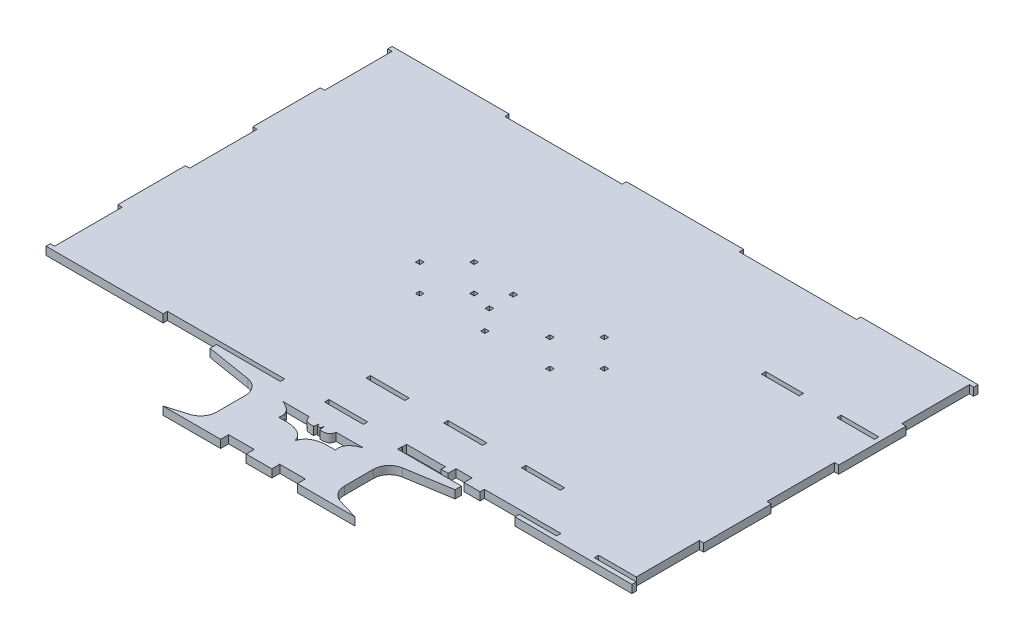
from build123d import *

# Parameters (mm, degrees)
SKETCH1_W           = 2.7
SKETCH1_H           = 2.7
SKETCH1_W_2         = 23.566666667
SKETCH1_W_3         = 24.3
BOSS_EXTRUDE1_DEPTH = 5


with BuildPart() as part:
    # Sketch1 → Boss-Extrude1 (new body)
    with BuildSketch(Plane(origin=(0, 0, 0), x_dir=(1, 0, 0), z_dir=(0, 1, 0))):
        with BuildLine():
            Line((-183.2, 108.2), (-109.92, 108.2))
            Line((-109.92, 108.2), (-109.92, 105.5))
            Line((-109.92, 105.5), (-36.64, 105.5))
            Line((-36.64, 105.5), (-36.64, 108.2))
            Line((-36.64, 108.2), (36.64, 108.2))
            Line((36.64, 108.2), (36.64, 105.5))
            Line((36.64, 105.5), (109.92, 105.5))
            Line((109.92, 105.5), (109.92, 108.2))
            Line((109.92, 108.2), (183.2, 108.2))
            Line((183.2, 108.2), (183.2, 105.5))
            Line((183.2, 105.5), (180.5, 105.5))
            Line((180.5, 105.5), (180.5, 63.3))
            Line((180.5, 63.3), (183.2, 63.3))
            Line((183.2, 63.3), (183.2, 21.1))
            Line((183.2, 21.1), (180.5, 21.1))
            Line((180.5, 21.1), (180.5, -21.1))
            Line((180.5, -21.1), (183.2, -21.1))
            Line((183.2, -21.1), (183.2, -63.3))
            Line((183.2, -63.3), (180.5, -63.3))
            Line((180.5, -63.3), (180.5, -102.8))
            Line((180.5, -102.8), (156.933333333, -102.8))
            Line((156.933333333, -102.8), (156.933333333, -105.5))
            Line((156.933333333, -105.5), (180.5, -105.5))
            Line((180.5, -105.5), (183.2, -105.5))
            Line((183.2, -105.5), (183.2, -108.2))
            Line((183.2, -108.2), (109.92, -108.2))
            Line((109.92, -108.2), (109.92, -105.5))
            Line((109.92, -105.5), (133.366666667, -105.5))
            Line((133.366666667, -105.5), (133.366666667, -102.8))
            Line((133.366666667, -102.8), (109.8, -102.8))
            Line((109.8, -102.8), (85.5, -102.8))
            Line((85.5, -102.8), (85.5, -105.5))
            Line((85.5, -105.5), (75.5, -105.5))
            Line((75.5, -105.5), (75.5, -100.5))
            Line((75.5, -100.5), (70.5, -100.5))
            Line((70.5, -100.5), (65.5, -100.5))
            Line((65.5, -100.5), (65.5, -105.5))
            Line((65.5, -105.5), (61.2, -105.5))
            Line((61.2, -105.5), (61.2, -102.8))
            Line((61.2, -102.8), (36.9, -102.8))
            Line((36.9, -102.8), (36.9, -105.5))
            Line((36.9, -105.5), (36.64, -105.5))
            Line((36.64, -105.5), (36.64, -108.2))
            Line((36.64, -108.2), (76.64, -108.2))
            Line((76.64, -108.2), (76.64, -112.2))
            Line((76.64, -112.2), (48.383969685, -116.8270792))
            ThreePointArc((48.383969685, -116.8270792), (42.378966502, -120.22108374), (40, -126.695637657))
            Line((40, -126.695637657), (40, -144.759693491))
            ThreePointArc((40, -144.759693491), (41.977070717, -150.728998787), (47.126521144, -154.337956343))
            Line((47.126521144, -154.337956343), (60, -158.2))
            Line((60, -158.2), (40, -158.2))
            Line((40, -158.2), (24, -158.2))
            Line((24, -158.2), (24, -153.2))
            Line((24, -153.2), (8, -153.2))
            Line((8, -153.2), (8, -158.2))
            Line((8, -158.2), (-8, -158.2))
            Line((-8, -158.2), (-8, -153.2))
            Line((-8, -153.2), (-24, -153.2))
            Line((-24, -153.2), (-24, -158.2))
            Line((-24, -158.2), (-40, -158.2))
            Line((-40, -158.2), (-60, -158.2))
            Line((-60, -158.2), (-47.126521144, -154.337956343))
            ThreePointArc((-47.126521144, -154.337956343), (-41.977070717, -150.728998787), (-40, -144.759693491))
            Line((-40, -144.759693491), (-40, -126.695637657))
            ThreePointArc((-40, -126.695637657), (-42.378966502, -120.22108374), (-48.383969685, -116.8270792))
            Line((-48.383969685, -116.8270792), (-76.64, -112.2))
            Line((-76.64, -112.2), (-76.64, -108.2))
            Line((-76.64, -108.2), (-36.64, -108.2))
            Line((-36.64, -108.2), (-36.64, -105.5))
            Line((-36.64, -105.5), (-109.92, -105.5))
            Line((-109.92, -105.5), (-109.92, -108.2))
            Line((-109.92, -108.2), (-183.2, -108.2))
            Line((-183.2, -108.2), (-183.2, -105.5))
            Line((-183.2, -105.5), (-180.5, -105.5))
            Line((-180.5, -105.5), (-180.5, -63.3))
            Line((-180.5, -63.3), (-183.2, -63.3))
            Line((-183.2, -63.3), (-183.2, -21.1))
            Line((-183.2, -21.1), (-180.5, -21.1))
            Line((-180.5, -21.1), (-180.5, 21.1))
            Line((-180.5, 21.1), (-183.2, 21.1))
            Line((-183.2, 21.1), (-183.2, 63.3))
            Line((-183.2, 63.3), (-180.5, 63.3))
            Line((-180.5, 63.3), (-180.5, 105.5))
            Line((-180.5, 105.5), (-183.2, 105.5))
            Line((-183.2, 105.5), (-183.2, 108.2))
        make_face()
        with BuildLine():
            Line((0.9301176, -120.716600974), (0, -120.68082722))
            Line((0, -120.68082722), (-0.9301176, -120.716600974))
            Line((-0.9301176, -120.716600974), (-1.4468496, -118.933875574))
            Line((-1.4468496, -118.933875574), (-1.505337966, -118.732090711))
            Line((-1.505337966, -118.732090711), (-1.5243594, -118.908038974))
            add(Edge.make_bspline(
                [(-2.0927646, -122.111777374), (-2.0066426, -121.999818774), (-1.859073837, -121.914980184), (-1.8343986, -121.775901574), (-1.666428749, -120.829162413), (-1.6277058, -119.863993174), (-1.5243594, -118.908038974)],
                knots=[0, 0, 0, 0, 1, 1, 1, 2, 2, 2, 2], degree=3))
            add(Edge.make_bspline(
                [(-8.3452218, -118.287960574), (-8.1729778, -118.856365774), (-8.075779611, -119.453175974), (-7.8284898, -119.993176174), (-7.648412968, -120.386405174), (-7.396003023, -120.758010223), (-7.0792284, -121.052476774), (-6.770919603, -121.339073684), (-6.396966748, -121.576394249), (-5.9940912, -121.698391774), (-5.156587311, -121.952002107), (-4.280620327, -122.071245104), (-3.4104312, -122.163450574), (-2.973318406, -122.209767162), (-2.5319868, -122.129001774), (-2.0927646, -122.111777374)],
                knots=[0, 0, 0, 0, 1, 1, 1, 2, 2, 2, 3, 3, 3, 4, 4, 4, 5, 5, 5, 5], degree=3))
            Line((-8.3452218, -118.287960574), (-25.0098288, -118.210450774))
            add(Edge.make_bspline(
                [(-17.7239076, -128.157541774), (-17.6463978, -127.503014574), (-17.486801223, -126.8530449), (-17.4913782, -126.193960174), (-17.495488714, -125.602046218), (-17.572706856, -125.001904806), (-17.7497442, -124.437071374), (-17.938674268, -123.834294492), (-18.223243755, -123.255529036), (-18.5765154, -122.731855774), (-18.962093872, -122.160292392), (-19.432781213, -121.642214377), (-19.9458552, -121.181659774), (-20.53296266, -120.654649929), (-21.178318096, -120.187467606), (-21.8577636, -119.786483374), (-22.869428608, -119.189435173), (-23.975534695, -118.767378369), (-25.0098288, -118.210450774)],
                knots=[0, 0, 0, 0, 1, 1, 1, 2, 2, 2, 3, 3, 3, 4, 4, 4, 5, 5, 5, 6, 6, 6, 6], degree=3))
            add(Edge.make_bspline(
                [(0, -135.727665574), (-0.258366, -135.081750574), (-0.446586906, -134.403141283), (-0.775098, -133.789920574), (-1.096611928, -133.189761242), (-1.489704454, -132.623203353), (-1.937745, -132.110541574), (-2.391023881, -131.591885932), (-2.905578598, -131.121252413), (-3.4621044, -130.715365174), (-4.057630696, -130.281033966), (-4.699347279, -129.901244204), (-5.3740128, -129.604391374), (-6.21408481, -129.23475969), (-7.091056719, -128.940135618), (-7.9835094, -128.725946974), (-9.035354612, -128.473504123), (-10.109700417, -128.304069497), (-11.1872478, -128.209214974), (-12.58604985, -128.086080991), (-13.995132408, -128.060594987), (-15.3986136, -128.105868574), (-16.173499897, -128.130864906), (-16.9488096, -128.140317374), (-17.7239076, -128.157541774)],
                knots=[0, 0, 0, 0, 1, 1, 1, 2, 2, 2, 3, 3, 3, 4, 4, 4, 5, 5, 5, 6, 6, 6, 7, 7, 7, 8, 8, 8, 8], degree=3))
            add(Edge.make_bspline(
                [(0, -135.727665574), (0.258366, -135.081750574), (0.446586906, -134.403141283), (0.775098, -133.789920574), (1.096611928, -133.189761242), (1.489704454, -132.623203353), (1.937745, -132.110541574), (2.391023881, -131.591885932), (2.905578598, -131.121252413), (3.4621044, -130.715365174), (4.057630696, -130.281033966), (4.699347279, -129.901244204), (5.3740128, -129.604391374), (6.21408481, -129.23475969), (7.091056719, -128.940135618), (7.9835094, -128.725946974), (9.035354612, -128.473504123), (10.109700417, -128.304069497), (11.1872478, -128.209214974), (12.58604985, -128.086080991), (13.995132408, -128.060594987), (15.3986136, -128.105868574), (16.173499897, -128.130864906), (16.9488096, -128.140317374), (17.7239076, -128.157541774)],
                knots=[0, 0, 0, 0, 1, 1, 1, 2, 2, 2, 3, 3, 3, 4, 4, 4, 5, 5, 5, 6, 6, 6, 7, 7, 7, 8, 8, 8, 8], degree=3))
            add(Edge.make_bspline(
                [(17.7239076, -128.157541774), (17.6463978, -127.503014574), (17.486801223, -126.8530449), (17.4913782, -126.193960174), (17.495488714, -125.602046218), (17.572706856, -125.001904806), (17.7497442, -124.437071374), (17.938674268, -123.834294492), (18.223243755, -123.255529036), (18.5765154, -122.731855774), (18.962093872, -122.160292392), (19.432781213, -121.642214377), (19.9458552, -121.181659774), (20.53296266, -120.654649929), (21.178318096, -120.187467606), (21.8577636, -119.786483374), (22.869428608, -119.189435173), (23.975534695, -118.767378369), (25.0098288, -118.210450774)],
                knots=[0, 0, 0, 0, 1, 1, 1, 2, 2, 2, 3, 3, 3, 4, 4, 4, 5, 5, 5, 6, 6, 6, 6], degree=3))
            Line((25.0098288, -118.210450774), (8.3452218, -118.287960574))
            add(Edge.make_bspline(
                [(8.3452218, -118.287960574), (8.1729778, -118.856365774), (8.075779611, -119.453175974), (7.8284898, -119.993176174), (7.648412968, -120.386405174), (7.396003023, -120.758010223), (7.0792284, -121.052476774), (6.770919603, -121.339073684), (6.396966748, -121.576394249), (5.9940912, -121.698391774), (5.156587311, -121.952002107), (4.280620327, -122.071245104), (3.4104312, -122.163450574), (2.973318406, -122.209767162), (2.5319868, -122.129001774), (2.0927646, -122.111777374)],
                knots=[0, 0, 0, 0, 1, 1, 1, 2, 2, 2, 3, 3, 3, 4, 4, 4, 5, 5, 5, 5], degree=3))
            add(Edge.make_bspline(
                [(2.0927646, -122.111777374), (2.0066426, -121.999818774), (1.859073837, -121.914980184), (1.8343986, -121.775901574), (1.666428749, -120.829162413), (1.6277058, -119.863993174), (1.5243594, -118.908038974)],
                knots=[0, 0, 0, 0, 1, 1, 1, 2, 2, 2, 2], degree=3))
            Line((1.5243594, -118.908038974), (1.505337966, -118.732090711))
            Line((1.505337966, -118.732090711), (1.4468496, -118.933875574))
            Line((1.4468496, -118.933875574), (0.9301176, -120.716600974))
        make_face(mode=Mode.SUBTRACT)
        with Locations((57.703668038, 0)):
            Rectangle(SKETCH1_W, SKETCH1_H, mode=Mode.SUBTRACT)
        with Locations((40.703668038, 17)):
            Rectangle(SKETCH1_W, SKETCH1_H, mode=Mode.SUBTRACT)
        with Locations((40.703668038, -17)):
            Rectangle(SKETCH1_W, SKETCH1_H, mode=Mode.SUBTRACT)
        with Locations((23.703668038, 0)):
            Rectangle(SKETCH1_W, SKETCH1_H, mode=Mode.SUBTRACT)
        with Locations((-23.703668038, 0)):
            Rectangle(SKETCH1_W, SKETCH1_H, mode=Mode.SUBTRACT)
        with Locations((-40.703668038, -17)):
            Rectangle(SKETCH1_W, SKETCH1_H, mode=Mode.SUBTRACT)
        with Locations((-40.703668038, 17)):
            Rectangle(SKETCH1_W, SKETCH1_H, mode=Mode.SUBTRACT)
        with Locations((-57.703668038, 0)):
            Rectangle(SKETCH1_W, SKETCH1_H, mode=Mode.SUBTRACT)
        with Locations((-0.001918656, -16.996940674)):
            Rectangle(SKETCH1_W, SKETCH1_H, mode=Mode.SUBTRACT)
        with Locations((-10.874420173, 11.65292472)):
            Rectangle(SKETCH1_W, SKETCH1_H, mode=Mode.SUBTRACT)
        with Locations((-10.874420173, -3.34707528)):
            Rectangle(SKETCH1_W, SKETCH1_H, mode=Mode.SUBTRACT)
        with Locations((168.716666667, 47.55)):
            Rectangle(SKETCH1_W_2, SKETCH1_H, mode=Mode.SUBTRACT)
        with Locations((121.583333334, 47.55)):
            Rectangle(SKETCH1_W_2, SKETCH1_H, mode=Mode.SUBTRACT)
        Polygon((109.8, -79.6), (109.8, -76.9), (85.5, -76.9), (85.5, -79.6), (107.1, -79.6), align=None, mode=Mode.SUBTRACT)
        Polygon((12.6, -105.5), (-11.7, -105.5), (-11.7, -102.8), (-9, -102.8), (12.6, -102.8), align=None, mode=Mode.SUBTRACT)
        Polygon((-11.7, -79.6), (-11.7, -76.9), (12.6, -76.9), (12.6, -79.6), (-9, -79.6), align=None, mode=Mode.SUBTRACT)
        with Locations((49.05, -78.25)):
            Rectangle(SKETCH1_W_3, SKETCH1_H, mode=Mode.SUBTRACT)
    extrude(amount=BOSS_EXTRUDE1_DEPTH)


solid = part.part
